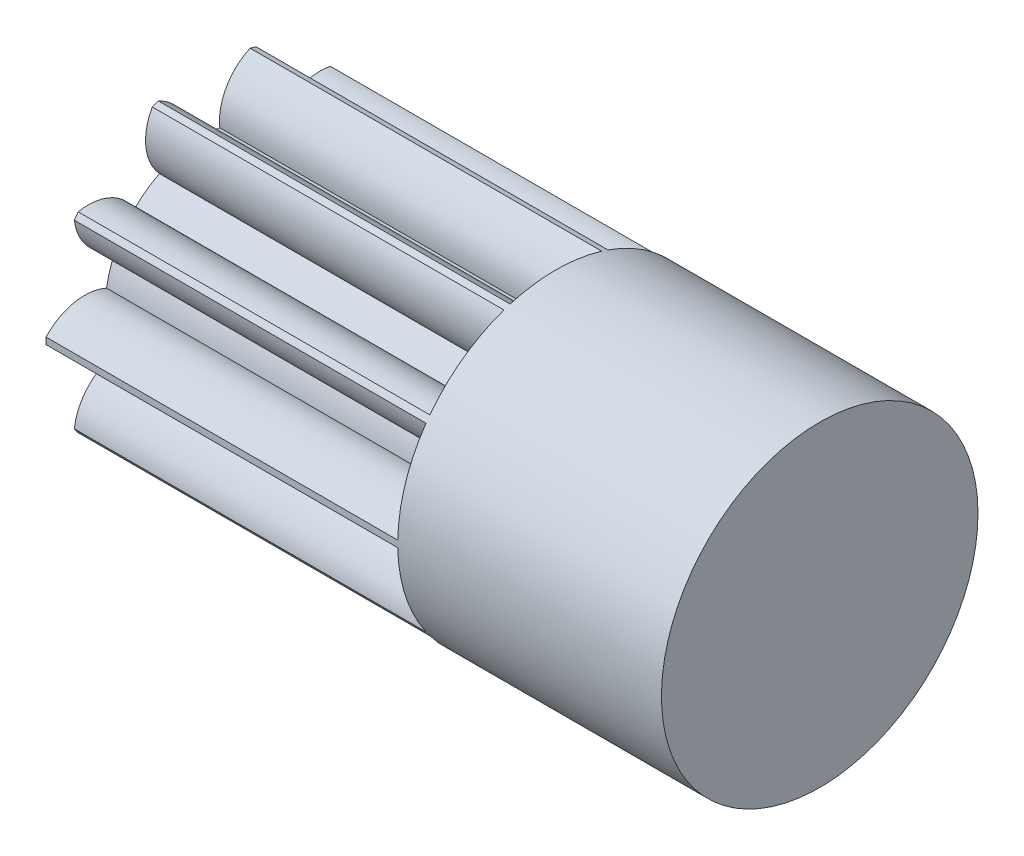
from build123d import *
from build123d.topology import SkipClean

# Parameters (mm, degrees)
BASPROSKE_W                 = 20
BASPROSKE_H                 = 9
TOOTHCUT_DEPTH              = 24.706539182
TEETHCUTS_COUNT             = 10
TEETHCUTS_ANGLE             = 324
BORSKE_R                    = 2.5
BORE_DEPTH                  = 50.0000508
IZIM1_R                     = 3
Y_KSEKLIK_EKSTR_ZYON3_DEPTH = 20
Y_KSEKLIK_EKSTR_ZYON4_START = 15
IZIM2_R                     = 9
Y_KSEKLIK_EKSTR_ZYON4_DEPTH = 15


with BuildPart() as part:
    # BasProSke → Base-Revolve (revolve)
    with BuildSketch(Plane(origin=(0, 0, 0), x_dir=(1, 0, 0), z_dir=(0, 1, 0)), mode=Mode.PRIVATE) as base_revolve_sk:
        with Locations((10, 4.5)):
            Rectangle(BASPROSKE_W, BASPROSKE_H)
    revolve(base_revolve_sk.sketch.rotate(Axis((-10, 0, 0), (1, 0, 0)), 180), axis=Axis((-10, 0, 0), (1, 0, 0)))

    # TooCutSke → ToothCut (cut, through all)
    with BuildSketch(Plane(origin=(0, 0, 0), x_dir=(0, 0, -1), z_dir=(1, 0, 0))):
        with BuildLine():
            ThreePointArc((0.883878355, 5.554109745), (0, 5.624), (-0.883878355, 5.554109745))
            ThreePointArc((-0.883878355, 5.554109745), (-1.258245767, 7.379188248), (-2.637816971, 8.631324741))
            ThreePointArc((-2.637816971, 8.631324741), (0, 9.0254), (2.637816971, 8.631324741))
            ThreePointArc((2.637816971, 8.631324741), (1.258245767, 7.379188248), (0.883878355, 5.554109745))
        make_face()
    toothcut = extrude(amount=TOOTHCUT_DEPTH, mode=Mode.SUBTRACT)

    # TeethCuts: ToothCut ×10 about axis
    teethcuts_axis = Axis((-10, 0, 0), (1, 0, 0))
    for i in range(1, TEETHCUTS_COUNT):
        add(toothcut.rotate(teethcuts_axis, i * TEETHCUTS_ANGLE / (TEETHCUTS_COUNT - 1)), mode=Mode.SUBTRACT)

    # BorSke → Bore (cut, symmetric)
    with BuildSketch(Plane(origin=(0, 0, 0), x_dir=(0, 0, -1), z_dir=(1, 0, 0))):
        with Locations(Location((0, 0, 0), (0, 0, 180))):
            Circle(BORSKE_R)
    extrude(amount=BORE_DEPTH, both=True, mode=Mode.SUBTRACT)

    # Çizim1 → Yükseklik-Ekstrüzyon3 (add)
    with BuildSketch(Plane(origin=(20, 0, 0), x_dir=(0, 0, -1), z_dir=(1, 0, 0))):
        Circle(IZIM1_R)
    extrude(amount=-Y_KSEKLIK_EKSTR_ZYON3_DEPTH)

    # Çizim2 → Yükseklik-Ekstrüzyon4 (add)
    with SkipClean():  # the faces are left unmerged after this step: merging them gives an invalid solid
        with BuildSketch(Plane(origin=(20, 0, 0), x_dir=(0, 0, -1), z_dir=(1, 0, 0)).offset(Y_KSEKLIK_EKSTR_ZYON4_START)):
            with Locations(Location((0, 0, 0), (0, 0, 178.810548778))):
                Circle(IZIM2_R)
        extrude(amount=-Y_KSEKLIK_EKSTR_ZYON4_DEPTH)


solid = part.part
